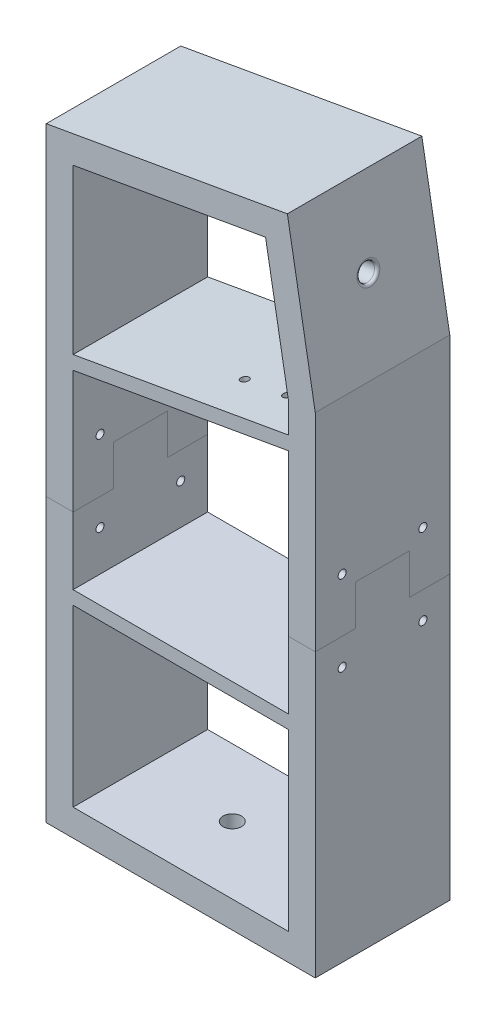
from build123d import *

# Parameters (mm, degrees)
BOSS_EXTRUDE1_DEPTH    = 50
SKETCH4_R              = 3.2
CUT_EXTRUDE1_DEPTH     = 10
BOSS_EXTRUDE2_DEPTH    = 50
SKETCH8_R              = 5
CUT_EXTRUDE3_DEPTH     = 10
CUT_EXTRUDE4_REACH     = 260.512
SKETCH9_R              = 1.485
SKETCH10_R             = 3.425
CUT_EXTRUDE5_DEPTH     = 10
SKETCH11_W             = 80
SKETCH11_H             = 5
BOSS_EXTRUDE3_DEPTH    = 50
FILLET1_R              = 1
SKETCH13_R             = 1.5
CUT_EXTRUDE6_DEPTH     = 266.502494397
SPLIT1_SURFACE_1_BACK  = 266.502
SPLIT1_SURFACE_1_DEPTH = 533.004
SPLIT1_SURFACE_2_BACK  = 266.502
SPLIT1_SURFACE_2_DEPTH = 533.004


with BuildPart() as part:
    # Sketch2 → Boss-Extrude1 (new body)
    with BuildSketch(Plane.XY):
        Polygon((-50, 225.01), (-50, 0), (50, 0), (50, 182.01), (39.631197958, 240.814398513), align=None)
        Polygon((-40, 216.619003688), (-40, 10), (40, 10), (40, 181.135113365), (31.519602204, 229.229839206), align=None, mode=Mode.SUBTRACT)
    extrude(amount=BOSS_EXTRUDE1_DEPTH)

    # Sketch4 → Cut-Extrude1 (cut)
    with BuildSketch(Plane(origin=(79.617858663, 14.038776629, 0), x_dir=(0, 0, -1), z_dir=(0.9848077530122079, 0.17364817766693136, 0))):
        with Locations(Location((-25, 200.891001389, 0), (0, 0, 90))):
            Circle(SKETCH4_R)
    extrude(amount=-CUT_EXTRUDE1_DEPTH, mode=Mode.SUBTRACT)

    # Sketch7 → Boss-Extrude2 (add)
    with BuildSketch(Plane.XY.offset(50)):
        Polygon((40, 169.799565432), (40, 164.722432372), (-40, 150.616273916), (-40, 155.693406975), align=None)
    extrude(amount=-BOSS_EXTRUDE2_DEPTH)

    # Sketch8 → Cut-Extrude3 (cut)
    with BuildSketch(Plane.ZY.offset(50)):
        with Locations(Location((25, 204.163858422, 0), (0, 0, 270))):
            Circle(SKETCH8_R)
    extrude(amount=-CUT_EXTRUDE3_DEPTH, mode=Mode.SUBTRACT)

    # Sketch9 → Cut-Extrude4 (cut, up to next)
    with BuildSketch(Plane(origin=(128.377379322, 180.305748831, 0), x_dir=(-0.9848077530122079, -0.17364817766693152, 0), z_dir=(-0.17364817766693152, 0.9848077530122079, 0)), mode=Mode.PRIVATE) as cut_extrude4_sk1:
        with Locations((104.969193438, 15.4)):
            Circle(SKETCH9_R)
    cut_extrude4_tool1 = extrude(cut_extrude4_sk1.sketch, amount=CUT_EXTRUDE4_REACH, mode=Mode.PRIVATE) & part.part
    # Sketch9 → Cut-Extrude4 (cut, up to next)
    with BuildSketch(Plane(origin=(128.377379322, 180.305748831, 0), x_dir=(-0.9848077530122079, -0.17364817766693152, 0), z_dir=(-0.17364817766693152, 0.9848077530122079, 0)), mode=Mode.PRIVATE) as cut_extrude4_sk2:
        with Locations((104.969193438, 34.6)):
            Circle(SKETCH9_R)
    cut_extrude4_tool2 = extrude(cut_extrude4_sk2.sketch, amount=CUT_EXTRUDE4_REACH, mode=Mode.PRIVATE) & part.part
    # Sketch9 → Cut-Extrude4 (cut, up to next)
    with BuildSketch(Plane(origin=(128.377379322, 180.305748831, 0), x_dir=(-0.9848077530122079, -0.17364817766693152, 0), z_dir=(-0.17364817766693152, 0.9848077530122079, 0)), mode=Mode.PRIVATE) as cut_extrude4_sk3:
        with Locations(Location((120.969193438, 34.6, 0), (0, 0, 180))):
            Circle(SKETCH9_R)
    cut_extrude4_tool3 = extrude(cut_extrude4_sk3.sketch, amount=CUT_EXTRUDE4_REACH, mode=Mode.PRIVATE) & part.part
    # Sketch9 → Cut-Extrude4 (cut, up to next)
    with BuildSketch(Plane(origin=(128.377379322, 180.305748831, 0), x_dir=(-0.9848077530122079, -0.17364817766693152, 0), z_dir=(-0.17364817766693152, 0.9848077530122079, 0)), mode=Mode.PRIVATE) as cut_extrude4_sk4:
        with Locations(Location((120.969193438, 15.4, 0), (0, 0, 180))):
            Circle(SKETCH9_R)
    cut_extrude4_tool4 = extrude(cut_extrude4_sk4.sketch, amount=CUT_EXTRUDE4_REACH, mode=Mode.PRIVATE) & part.part
    add(cut_extrude4_tool1.solids().sort_by_distance((25.002904, 162.07804, 15.4))[0], mode=Mode.SUBTRACT)
    add(cut_extrude4_tool2.solids().sort_by_distance((25.002904, 162.07804, 34.6))[0], mode=Mode.SUBTRACT)
    add(cut_extrude4_tool3.solids().sort_by_distance((9.24598, 159.299669, 34.6))[0], mode=Mode.SUBTRACT)
    add(cut_extrude4_tool4.solids().sort_by_distance((9.24598, 159.299669, 15.4))[0], mode=Mode.SUBTRACT)

    # Sketch10 → Cut-Extrude5 (cut)
    with BuildSketch(Plane(origin=(0, 10, 0), x_dir=(1, 0, 0), z_dir=(0, 1, 0))):
        with Locations(Location((-5.851287133, -25, 0), (0, 0, 180))):
            Circle(SKETCH10_R)
        with Locations(Location((24.130974018, -25, 0), (0, 0, 180))):
            Circle(SKETCH10_R)
    extrude(amount=-CUT_EXTRUDE5_DEPTH, mode=Mode.SUBTRACT)

    # Sketch11 → Boss-Extrude3 (add)
    with BuildSketch(Plane.XY.offset(50)):
        with Locations((0, 77.5)):
            Rectangle(SKETCH11_W, SKETCH11_H)
    extrude(amount=-BOSS_EXTRUDE3_DEPTH)

    # Fillet1
    fillet1_edges = [part.edges().sort_by_distance(p)[0] for p in [
        (45.289176531, 208.726407497, 25),
    ]]
    fillet(fillet1_edges, radius=FILLET1_R)

    # Sketch13 → Cut-Extrude6 (cut, through all)
    with BuildSketch(Plane.ZY.offset(50)):
        with Locations(Location((40, 125, 0), (0, 0, 270))):
            Circle(SKETCH13_R)
        with Locations(Location((40, 95, 0), (0, 0, 270))):
            Circle(SKETCH13_R)
        with Locations((10, 95)):
            Circle(SKETCH13_R)
        with Locations((10, 125)):
            Circle(SKETCH13_R)
    extrude(amount=-CUT_EXTRUDE6_DEPTH, mode=Mode.SUBTRACT)


with BuildPart() as body_2:
    # Split1: the piece behind the surface
    add(part.part)
    # Split1 surface: a surface, the sketch's curves swept straight by 533.004 mm
    with BuildLine(Plane.ZY.offset(50).offset(-SPLIT1_SURFACE_1_BACK), mode=Mode.PRIVATE) as split1_surface_1_path:
        Line((50, 105), (35, 105))
        Line((35, 105), (35, 120))
        Line((35, 120), (15, 120))
        Line((15, 120), (15, 105))
        Line((15, 105), (0, 105))
    split1_surface_1 = Shell.extrude(split1_surface_1_path.wire(), (-1 * SPLIT1_SURFACE_1_DEPTH, 0 * SPLIT1_SURFACE_1_DEPTH, 0 * SPLIT1_SURFACE_1_DEPTH))
    split(bisect_by=split1_surface_1, keep=Keep.BOTTOM)


with BuildPart() as part_1:
    add(part.part)

    # Split1: split by a surface, the side it looks to stays
    # Split1 surface: a surface, the sketch's curves swept straight by 533.004 mm
    with BuildLine(Plane.ZY.offset(50).offset(-SPLIT1_SURFACE_2_BACK), mode=Mode.PRIVATE) as split1_surface_2_path:
        Line((50, 105), (35, 105))
        Line((35, 105), (35, 120))
        Line((35, 120), (15, 120))
        Line((15, 120), (15, 105))
        Line((15, 105), (0, 105))
    split1_surface_2 = Shell.extrude(split1_surface_2_path.wire(), (-1 * SPLIT1_SURFACE_2_DEPTH, 0 * SPLIT1_SURFACE_2_DEPTH, 0 * SPLIT1_SURFACE_2_DEPTH))
    split(bisect_by=split1_surface_2, keep=Keep.TOP)


solid = Compound([body_2.part, part_1.part])
